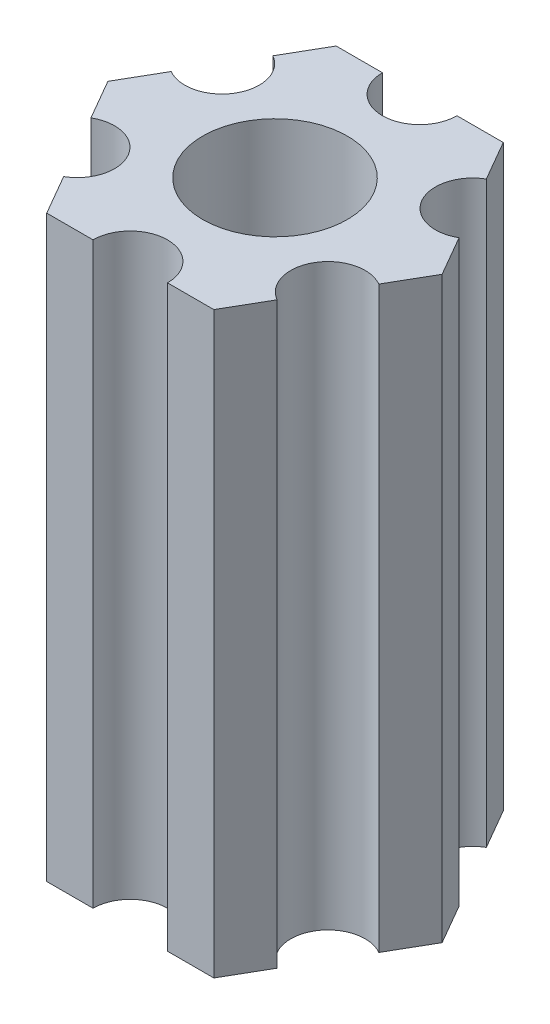
from build123d import *

# Parameters (mm, degrees)
SKETCH1_R           = 3.175
BOSS_EXTRUDE1_DEPTH = 25.4


with BuildPart() as part:
    # Sketch1 → Boss-Extrude1 (new body)
    with BuildSketch(Plane.XZ.offset(25.4)):
        with BuildLine():
            Line((-4.682174209, -4.59023638), (-3.666174209, -6.35))
            Line((-3.666174209, -6.35), (-1.634174209, -6.35))
            ThreePointArc((-1.634174209, -6.35), (0, -4.715825791), (1.634174209, -6.35))
            Line((1.634174209, -6.35), (3.666174209, -6.35))
            Line((3.666174209, -6.35), (4.682174209, -4.59023638))
            ThreePointArc((4.682174209, -4.59023638), (4.084024935, -2.357912895), (6.316348419, -1.75976362))
            Line((6.316348419, -1.75976362), (7.332348419, 0))
            Line((7.332348419, 0), (6.316348419, 1.75976362))
            ThreePointArc((6.316348419, 1.75976362), (4.084024935, 2.357912895), (4.682174209, 4.59023638))
            Line((4.682174209, 4.59023638), (3.666174209, 6.35))
            Line((3.666174209, 6.35), (1.634174209, 6.35))
            ThreePointArc((1.634174209, 6.35), (0, 4.715825791), (-1.634174209, 6.35))
            Line((-1.634174209, 6.35), (-3.666174209, 6.35))
            Line((-3.666174209, 6.35), (-4.682174209, 4.59023638))
            ThreePointArc((-4.682174209, 4.59023638), (-4.084024935, 2.357912895), (-6.316348419, 1.75976362))
            Line((-6.316348419, 1.75976362), (-7.332348419, 0))
            Line((-7.332348419, 0), (-6.316348419, -1.75976362))
            ThreePointArc((-6.316348419, -1.75976362), (-4.084024935, -2.357912895), (-4.682174209, -4.59023638))
        make_face()
        Circle(SKETCH1_R, mode=Mode.SUBTRACT)
    extrude(amount=-BOSS_EXTRUDE1_DEPTH)


solid = part.part
